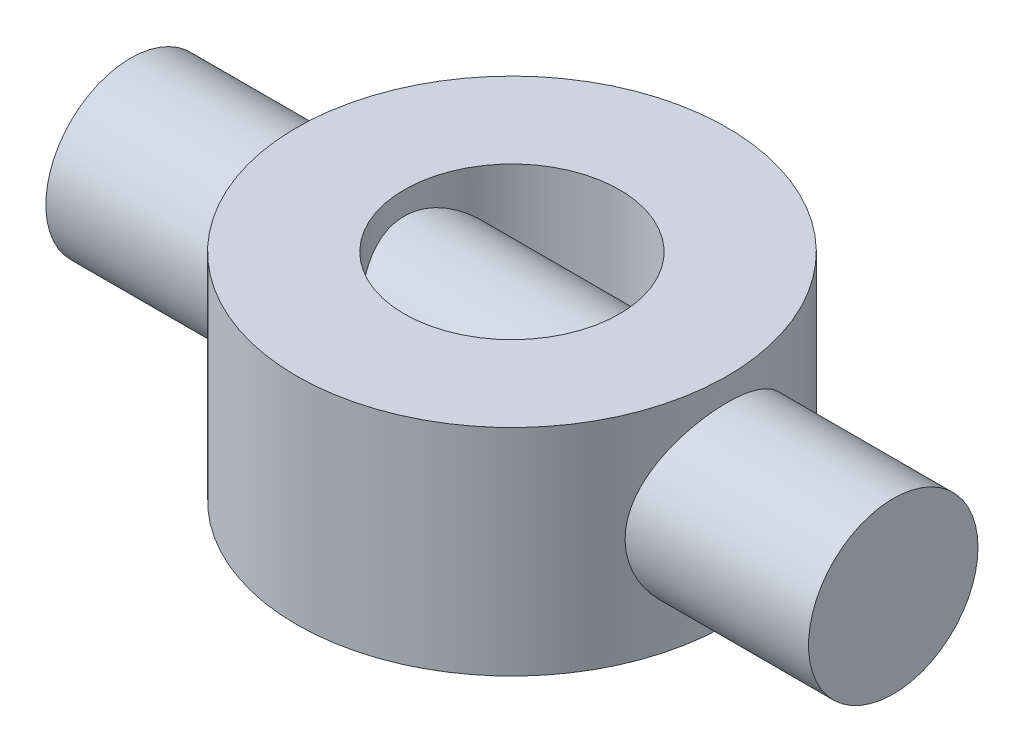
from build123d import *

# Parameters (mm, degrees)
BOSS_EXTRUDE1_DEPTH      = 45
BOSS_EXTRUDE1_DEPTH_BACK = 45
SKETCH2_R                = 10
BOSS_EXTRUDE2_DEPTH      = 12.7
BOSS_EXTRUDE2_DEPTH_BACK = 12.7
SKETCH1_R                = 25.4
SKETCH1_R_2              = 12.7


with BuildPart() as part:
    # Sketch2 → Boss-Extrude1 (new, two sides: drawn at the far end of the back side and taken through both)
    with BuildSketch(Plane(origin=(0, 0, 0), x_dir=(0, 0, -1), z_dir=(1, 0, 0)).offset(-BOSS_EXTRUDE1_DEPTH_BACK)):
        Circle(SKETCH2_R)
    extrude(amount=BOSS_EXTRUDE1_DEPTH + BOSS_EXTRUDE1_DEPTH_BACK)

    # Sketch1 → Boss-Extrude2 (add, two sides: drawn at the far end of the back side and taken through both)
    with BuildSketch(Plane(origin=(0, 0, 0), x_dir=(1, 0, 0), z_dir=(0, 1, 0)).offset(-BOSS_EXTRUDE2_DEPTH_BACK)):
        Circle(SKETCH1_R)
        Circle(SKETCH1_R_2, mode=Mode.SUBTRACT)
    extrude(amount=BOSS_EXTRUDE2_DEPTH + BOSS_EXTRUDE2_DEPTH_BACK)


solid = part.part
